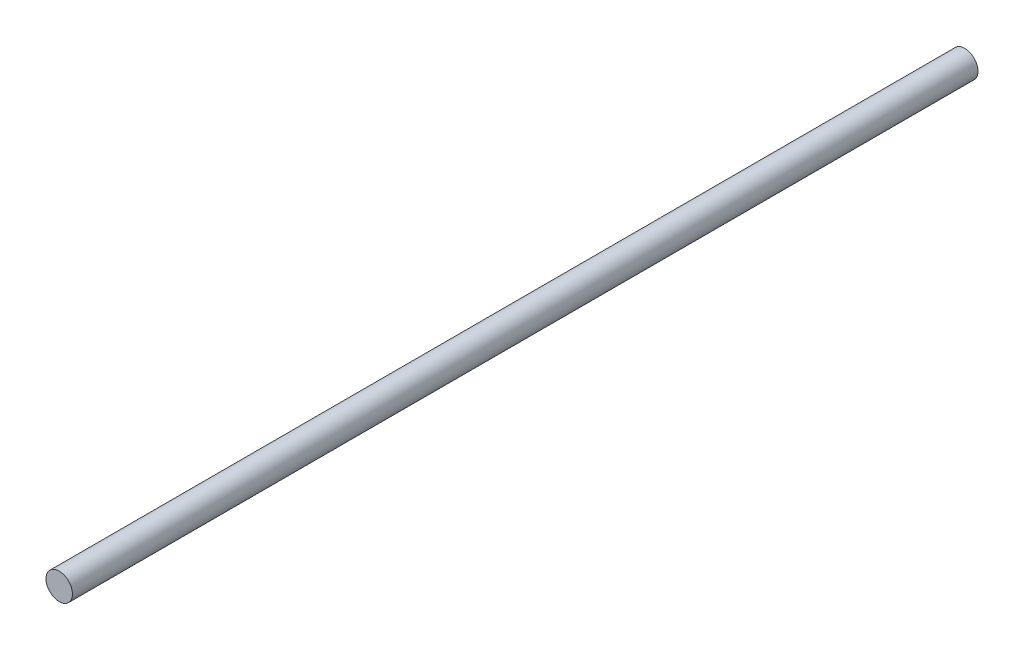
from build123d import *

# Parameters (mm, degrees)
SKETCH1_R           = 2.5
BOSS_EXTRUDE1_DEPTH = 171


with BuildPart() as part:
    # Sketch1 → Boss-Extrude1 (new body)
    with BuildSketch(Plane.XY):
        Circle(SKETCH1_R)
    extrude(amount=-BOSS_EXTRUDE1_DEPTH)


solid = part.part
